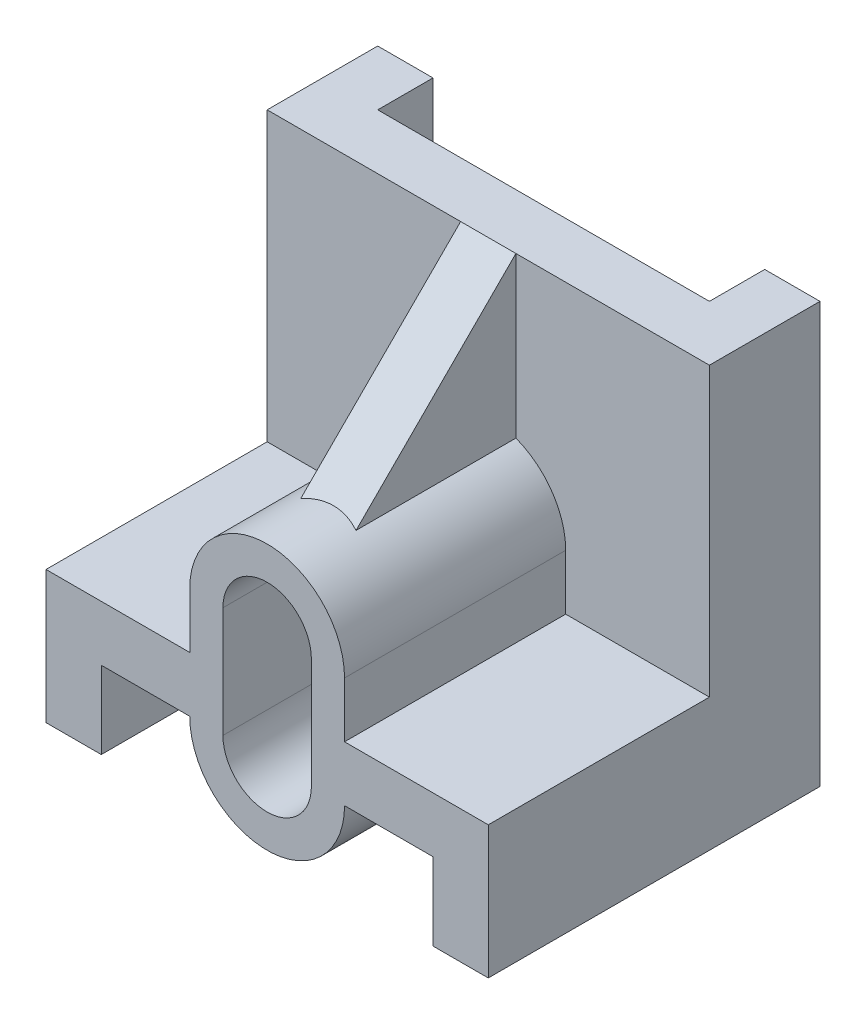
from build123d import *

# Parameters (mm, degrees)
BOSS_EXTRUDE1_DEPTH = 20
SKETCH2_W           = 30
SKETCH2_H           = 7
CUT_EXTRUDE1_DEPTH  = 31
BOSS_EXTRUDE3_DEPTH = 30
CUT_EXTRUDE2_DEPTH  = 31
SKETCH5_W           = 30
SKETCH5_H           = 5
CUT_EXTRUDE3_DEPTH  = 39
RIB2_REACH          = 22
SKETCH6_WALL_W      = 61.798989874
SKETCH6_WALL_H      = 5


with BuildPart() as part:
    # Sketch1 → Boss-Extrude1 (new body, symmetric)
    with BuildSketch(Plane(origin=(0, 0, 0), x_dir=(0, 0, -1), z_dir=(1, 0, 0))):
        Polygon((0, 38), (0, 0), (-30, 0), (-30, 12), (-10, 12), (-10, 38), align=None)
    extrude(amount=BOSS_EXTRUDE1_DEPTH, both=True)

    # Sketch2 → Cut-Extrude1 (cut, through all)
    with BuildSketch(Plane.XY.offset(30)):
        with Locations((0, 3.5)):
            Rectangle(SKETCH2_W, SKETCH2_H)
    extrude(amount=-CUT_EXTRUDE1_DEPTH, mode=Mode.SUBTRACT)

    # Sketch3 → Boss-Extrude3 (add)
    with BuildSketch(Plane.XY.offset(30)):
        with BuildLine():
            Line((7, 17), (7, 7))
            ThreePointArc((7, 7), (0, 0), (-7, 7))
            Line((-7, 7), (-7, 17))
            ThreePointArc((-7, 17), (0, 24), (7, 17))
        make_face()
    extrude(amount=-BOSS_EXTRUDE3_DEPTH)

    # Sketch4 → Cut-Extrude2 (cut, through all)
    with BuildSketch(Plane.XY.offset(30)):
        with BuildLine():
            Line((4, 17), (4, 7))
            ThreePointArc((4, 7), (0, 3), (-4, 7))
            Line((-4, 7), (-4, 17))
            ThreePointArc((-4, 17), (0, 21), (4, 17))
        make_face()
    extrude(amount=-CUT_EXTRUDE2_DEPTH, mode=Mode.SUBTRACT)

    # Sketch5 → Cut-Extrude3 (cut, through all)
    with BuildSketch(Plane(origin=(0, 38, 0), x_dir=(1, 0, 0), z_dir=(0, 1, 0))):
        with Locations((0, -2.5)):
            Rectangle(SKETCH5_W, SKETCH5_H)
    extrude(amount=-CUT_EXTRUDE3_DEPTH, mode=Mode.SUBTRACT)

    # Sketch6 wall → Rib2 (add, up to next)
    with BuildSketch(Plane(origin=(0, 31, 17), x_dir=(0, -0.707106781, 0.707106781), z_dir=(0, -0.707106781, -0.707106781)), mode=Mode.PRIVATE) as rib2_sk1:
        Rectangle(SKETCH6_WALL_W, SKETCH6_WALL_H)
    rib2_tool1 = extrude(rib2_sk1.sketch, amount=RIB2_REACH, mode=Mode.PRIVATE) - part.part
    add(rib2_tool1.solids().sort_by_distance((0, 31, 17))[0])


solid = part.part
